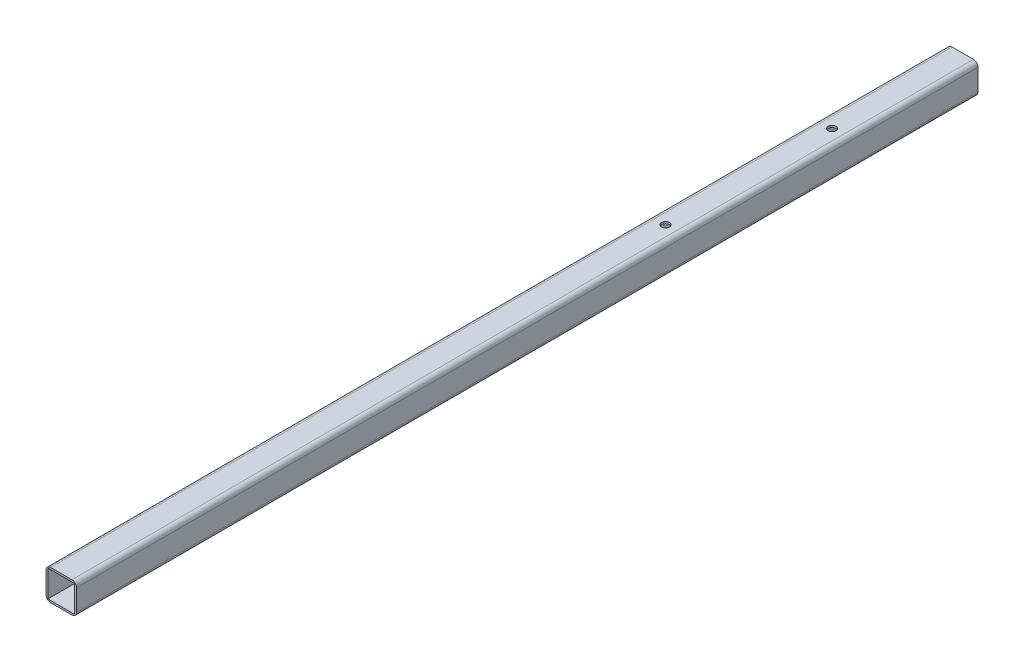
from build123d import *

# Parameters (mm, degrees)
SKETCH4_W               = 25.4
SKETCH4_H               = 25.4
SKETCH4_W_2             = 22.225
SKETCH4_H_2             = 22.225
BOSS_EXTRUDE2_DEPTH     = 374.65
FILLET1_R               = 3.81
SKETCH5_R               = 3.2639
CUT_EXTRUDE1_DEPTH      = 1
CUT_EXTRUDE1_DEPTH_BACK = 26.4


with BuildPart() as part:
    # Sketch4 → Boss-Extrude2 (new body, symmetric)
    with BuildSketch(Plane.XY):
        Rectangle(SKETCH4_W, SKETCH4_H)
        Rectangle(SKETCH4_W_2, SKETCH4_H_2, mode=Mode.SUBTRACT)
    extrude(amount=BOSS_EXTRUDE2_DEPTH, both=True)

    # Fillet1
    fillet1_edges = [part.edges().sort_by_distance(p)[0] for p in [
        (12.7, -12.7, 0),
        (-12.7, -12.7, 0),
        (-12.7, 12.7, 0),
        (12.7, 12.7, 0),
    ]]
    fillet(fillet1_edges, radius=FILLET1_R)

    # Sketch5 → Cut-Extrude1 (cut, two sides)
    with BuildSketch(Plane(origin=(0, 12.7, 0), x_dir=(1, 0, 0), z_dir=(0, 1, 0))) as cut_extrude1_sk:
        with Locations((0, 127.59545203)):
            Circle(SKETCH5_R)
        with Locations((0, 266.10454797)):
            Circle(SKETCH5_R)
    extrude(amount=CUT_EXTRUDE1_DEPTH, mode=Mode.SUBTRACT)
    extrude(cut_extrude1_sk.sketch, amount=-CUT_EXTRUDE1_DEPTH_BACK, mode=Mode.SUBTRACT)


solid = part.part
